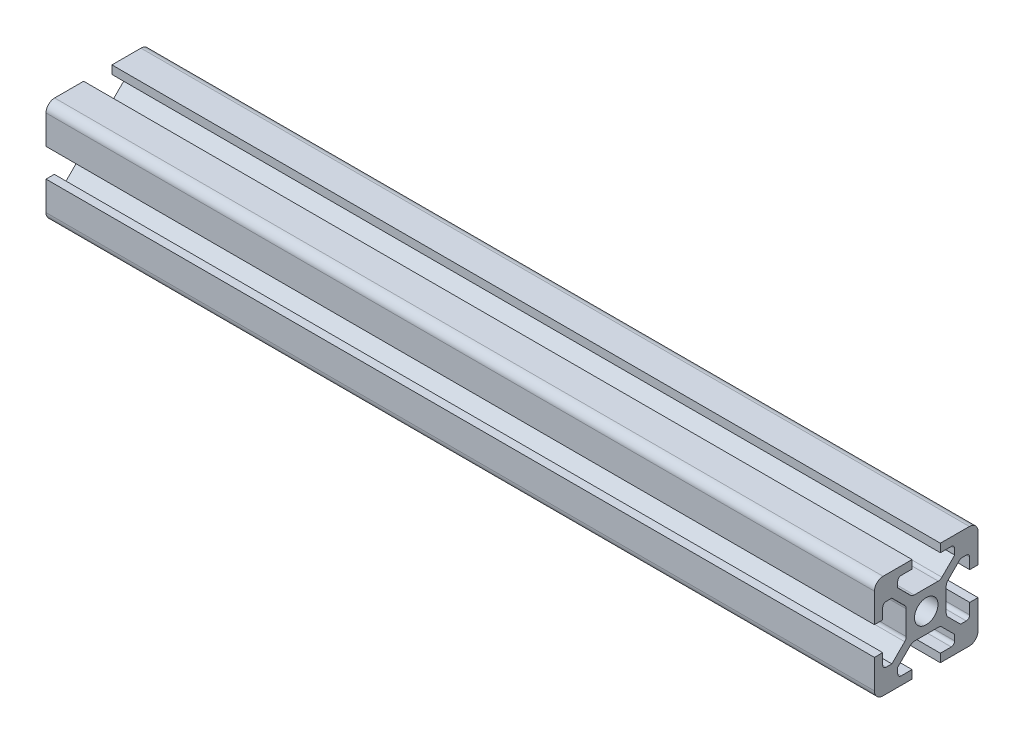
from build123d import *

# Parameters (mm, degrees)
SKETCH1_R           = 3.4
BOSS_EXTRUDE2_DEPTH = 100
FILLET5_R           = 2.5
FILLET6_R           = 1.5
FILLET7_R           = 1.5
FILLET8_R           = 1
SKETCH3_R           = 3.4
BOSS_EXTRUDE3_DEPTH = 140


with BuildPart() as part:
    # Sketch1 → Boss-Extrude2 (new body)
    with BuildSketch(Plane(origin=(0, 0, 0), x_dir=(0, 0, -1), z_dir=(1, 0, 0))):
        Polygon((10.9, 0), (10.9, 2.4), (6.75, 2.4), (6.75, 5.05), (10.9, 9.2), (19.1, 9.2), (23.25, 5.05), (23.25, 2.4), (19.1, 2.4), (19.1, 0), (30, 0), (30, 10.9), (27.6, 10.9), (27.6, 6.75), (24.95, 6.75), (20.8, 10.9), (20.8, 19.1), (24.95, 23.25), (27.6, 23.25), (27.6, 19.1), (30, 19.1), (30, 30), (19.1, 30), (19.1, 27.6), (23.25, 27.6), (23.25, 24.95), (19.1, 20.8), (10.9, 20.8), (6.75, 24.95), (6.75, 27.6), (10.9, 27.6), (10.9, 30), (0, 30), (0, 19.1), (2.4, 19.1), (2.4, 23.25), (5.05, 23.25), (9.2, 19.1), (9.2, 10.9), (5.05, 6.75), (2.4, 6.75), (2.4, 10.9), (0, 10.9), (0, 0), align=None)
        with Locations((15, 15)):
            Circle(SKETCH1_R, mode=Mode.SUBTRACT)
    extrude(amount=BOSS_EXTRUDE2_DEPTH)

    # Fillet5
    fillet5_edges = [part.edges().sort_by_distance(p)[0] for p in [
        (50, 30, 0),
        (50, 30, -30),
        (50, 0, -30),
        (50, 0, 0),
    ]]
    fillet(fillet5_edges, radius=FILLET5_R)

    # Fillet6
    fillet6_edges = [part.edges().sort_by_distance(p)[0] for p in [
        (50, 10.9, -9.2),
        (50, 19.1, -9.2),
        (50, 19.1, -20.8),
        (50, 10.9, -20.8),
        (50, 9.2, -19.1),
        (50, 9.2, -10.9),
    ]]
    fillet(fillet6_edges, radius=FILLET6_R)

    # Fillet7
    fillet7_edges = [part.edges().sort_by_distance(p)[0] for p in [
        (50, 20.8, -10.9),
        (50, 20.8, -19.1),
    ]]
    fillet(fillet7_edges, radius=FILLET7_R)

    # Fillet8
    fillet8_edges = [part.edges().sort_by_distance(p)[0] for p in [
        (50, 6.75, -2.4),
        (50, 23.25, -2.4),
        (50, 27.6, -6.75),
        (50, 27.6, -23.25),
        (50, 23.25, -27.6),
        (50, 6.75, -27.6),
        (50, 2.4, -23.25),
        (50, 2.4, -6.75),
    ]]
    fillet(fillet8_edges, radius=FILLET8_R)

    # Sketch3 → Boss-Extrude3 (add)
    with BuildSketch(Plane(origin=(0, 0, 0), x_dir=(0, 0, -1), z_dir=(1, 0, 0))):
        with BuildLine():
            Line((10.9, 27.6), (10.9, 30))
            Line((10.9, 30), (2.5, 30))
            ThreePointArc((2.5, 30), (0.732233047, 29.267766953), (0, 27.5))
            Line((0, 27.5), (0, 19.1))
            Line((0, 19.1), (2.4, 19.1))
            Line((2.4, 19.1), (2.4, 22.25))
            ThreePointArc((2.4, 22.25), (2.692893219, 22.957106781), (3.4, 23.25))
            Line((3.4, 23.25), (5.05, 23.25))
            Line((5.05, 23.25), (8.760660172, 19.539339828))
            ThreePointArc((8.760660172, 19.539339828), (9.085819299, 19.052704805), (9.2, 18.478679656))
            Line((9.2, 18.478679656), (9.2, 11.521320344))
            ThreePointArc((9.2, 11.521320344), (9.085819299, 10.947295195), (8.760660172, 10.460660172))
            Line((8.760660172, 10.460660172), (5.05, 6.75))
            Line((5.05, 6.75), (3.4, 6.75))
            ThreePointArc((3.4, 6.75), (2.692893219, 7.042893219), (2.4, 7.75))
            Line((2.4, 7.75), (2.4, 10.9))
            Line((2.4, 10.9), (0, 10.9))
            Line((0, 10.9), (0, 2.5))
            ThreePointArc((0, 2.5), (0.732233047, 0.732233047), (2.5, 0))
            Line((2.5, 0), (10.9, 0))
            Line((10.9, 0), (10.9, 2.4))
            Line((10.9, 2.4), (7.75, 2.4))
            ThreePointArc((7.75, 2.4), (7.042893219, 2.692893219), (6.75, 3.4))
            Line((6.75, 3.4), (6.75, 5.05))
            Line((6.75, 5.05), (10.460660172, 8.760660172))
            ThreePointArc((10.460660172, 8.760660172), (10.947295195, 9.085819299), (11.521320344, 9.2))
            Line((11.521320344, 9.2), (18.478679656, 9.2))
            ThreePointArc((18.478679656, 9.2), (19.052704805, 9.085819299), (19.539339828, 8.760660172))
            Line((19.539339828, 8.760660172), (23.25, 5.05))
            Line((23.25, 5.05), (23.25, 3.4))
            ThreePointArc((23.25, 3.4), (22.957106781, 2.692893219), (22.25, 2.4))
            Line((22.25, 2.4), (19.1, 2.4))
            Line((19.1, 2.4), (19.1, 0))
            Line((19.1, 0), (27.5, 0))
            ThreePointArc((27.5, 0), (29.267766953, 0.732233047), (30, 2.5))
            Line((30, 2.5), (30, 10.9))
            Line((30, 10.9), (27.6, 10.9))
            Line((27.6, 10.9), (27.6, 7.75))
            ThreePointArc((27.6, 7.75), (27.307106781, 7.042893219), (26.6, 6.75))
            Line((26.6, 6.75), (24.95, 6.75))
            Line((24.95, 6.75), (21.239339828, 10.460660172))
            ThreePointArc((21.239339828, 10.460660172), (20.914180701, 10.947295195), (20.8, 11.521320344))
            Line((20.8, 11.521320344), (20.8, 18.478679656))
            ThreePointArc((20.8, 18.478679656), (20.914180701, 19.052704805), (21.239339828, 19.539339828))
            Line((21.239339828, 19.539339828), (24.95, 23.25))
            Line((24.95, 23.25), (26.6, 23.25))
            ThreePointArc((26.6, 23.25), (27.307106781, 22.957106781), (27.6, 22.25))
            Line((27.6, 22.25), (27.6, 19.1))
            Line((27.6, 19.1), (30, 19.1))
            Line((30, 19.1), (30, 27.5))
            ThreePointArc((30, 27.5), (29.267766953, 29.267766953), (27.5, 30))
            Line((27.5, 30), (19.1, 30))
            Line((19.1, 30), (19.1, 27.6))
            Line((19.1, 27.6), (22.25, 27.6))
            ThreePointArc((22.25, 27.6), (22.957106781, 27.307106781), (23.25, 26.6))
            Line((23.25, 26.6), (23.25, 24.95))
            Line((23.25, 24.95), (19.539339828, 21.239339828))
            ThreePointArc((19.539339828, 21.239339828), (19.052704805, 20.914180701), (18.478679656, 20.8))
            Line((18.478679656, 20.8), (11.521320344, 20.8))
            ThreePointArc((11.521320344, 20.8), (10.947295195, 20.914180701), (10.460660172, 21.239339828))
            Line((10.460660172, 21.239339828), (6.75, 24.95))
            Line((6.75, 24.95), (6.75, 26.6))
            ThreePointArc((6.75, 26.6), (7.042893219, 27.307106781), (7.75, 27.6))
            Line((7.75, 27.6), (10.9, 27.6))
        make_face()
        with Locations((15, 15)):
            Circle(SKETCH3_R, mode=Mode.SUBTRACT)
    extrude(amount=-BOSS_EXTRUDE3_DEPTH)


solid = part.part
